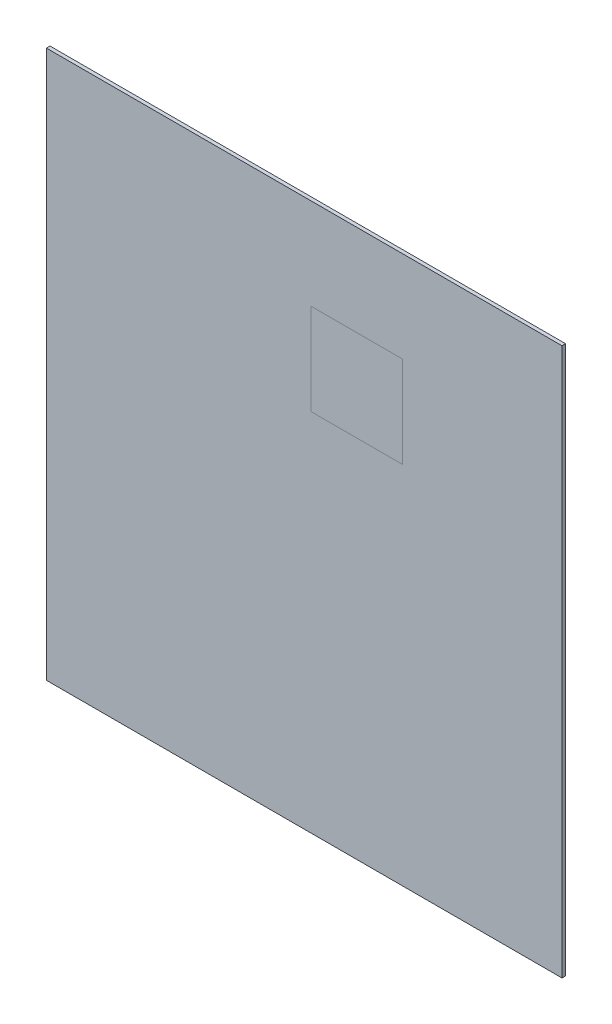
from build123d import *

# Parameters (mm, degrees)
SKETCH1_W              = 226
SKETCH1_H              = 240
BOSS_EXTRUDE1_DEPTH    = 1.57
SPLIT1_SURFACE_1_BACK  = 330.664
SPLIT1_SURFACE_1_DEPTH = 661.328
SPLIT1_SURFACE_2_BACK  = 330.664
SPLIT1_SURFACE_2_DEPTH = 661.328


with BuildPart() as part:
    # Sketch1 → Boss-Extrude1 (new body)
    with BuildSketch(Plane.XY):
        Rectangle(SKETCH1_W, SKETCH1_H)
    extrude(amount=BOSS_EXTRUDE1_DEPTH)


with BuildPart() as body_2:
    # Split1: the piece behind the surface
    add(part.part)
    # Split1 surface: a surface, the sketch's curves swept straight by 661.328 mm
    with BuildLine(Plane.XY.offset(1.57).offset(-SPLIT1_SURFACE_1_BACK), mode=Mode.PRIVATE) as split1_surface_1_path:
        Line((3, 40), (43, 40))
        Line((43, 40), (43, 80))
        Line((43, 80), (3, 80))
        Line((3, 80), (3, 40))
    split1_surface_1 = Shell.extrude(split1_surface_1_path.wire(), (0 * SPLIT1_SURFACE_1_DEPTH, 0 * SPLIT1_SURFACE_1_DEPTH, 1 * SPLIT1_SURFACE_1_DEPTH))
    split(bisect_by=split1_surface_1, keep=Keep.BOTTOM)


with BuildPart() as part_1:
    add(part.part)

    # Split1: split by a surface, the side it looks to stays
    # Split1 surface: a surface, the sketch's curves swept straight by 661.328 mm
    with BuildLine(Plane.XY.offset(1.57).offset(-SPLIT1_SURFACE_2_BACK), mode=Mode.PRIVATE) as split1_surface_2_path:
        Line((3, 40), (43, 40))
        Line((43, 40), (43, 80))
        Line((43, 80), (3, 80))
        Line((3, 80), (3, 40))
    split1_surface_2 = Shell.extrude(split1_surface_2_path.wire(), (0 * SPLIT1_SURFACE_2_DEPTH, 0 * SPLIT1_SURFACE_2_DEPTH, 1 * SPLIT1_SURFACE_2_DEPTH))
    split(bisect_by=split1_surface_2, keep=Keep.TOP)


solid = Compound([body_2.part, part_1.part])
